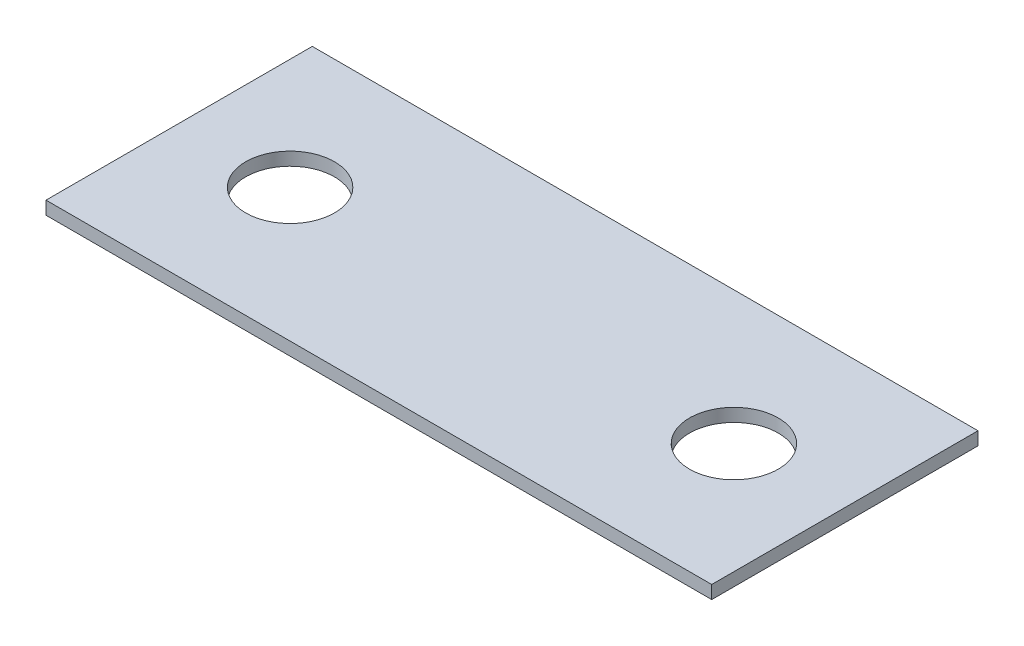
from build123d import *

# Parameters (mm, degrees)
SKETCH1_W           = 47.625
SKETCH1_H           = 19.05
BOSS_EXTRUDE1_DEPTH = 0.9375
CUT_EXTRUDE1_REACH  = 2.938
SKETCH2_R           = 3.175


with BuildPart() as part:
    # Sketch1 → Boss-Extrude1 (new body)
    with BuildSketch(Plane(origin=(0, 0, 0), x_dir=(1, 0, 0), z_dir=(0, 1, 0))):
        with Locations((23.8125, -9.525)):
            Rectangle(SKETCH1_W, SKETCH1_H)
    extrude(amount=BOSS_EXTRUDE1_DEPTH)

    # Sketch2 → Cut-Extrude1 (cut, up to next)
    with BuildSketch(Plane(origin=(0, 0.9375, 0), x_dir=(1, 0, 0), z_dir=(0, 1, 0)), mode=Mode.PRIVATE) as cut_extrude1_sk1:
        with Locations((7.9375, -9.525)):
            Circle(SKETCH2_R)
    cut_extrude1_tool1 = extrude(cut_extrude1_sk1.sketch, amount=-CUT_EXTRUDE1_REACH, mode=Mode.PRIVATE) & part.part
    add(cut_extrude1_tool1.solids().sort_by_distance((7.9375, 0.9375, 9.525))[0], mode=Mode.SUBTRACT)
    # Sketch2 → Cut-Extrude1 (cut, up to next)
    with BuildSketch(Plane(origin=(0, 0.9375, 0), x_dir=(1, 0, 0), z_dir=(0, 1, 0)), mode=Mode.PRIVATE) as cut_extrude1_sk2:
        with Locations((39.6875, -9.525)):
            Circle(SKETCH2_R)
    cut_extrude1_tool2 = extrude(cut_extrude1_sk2.sketch, amount=-CUT_EXTRUDE1_REACH, mode=Mode.PRIVATE) & part.part
    add(cut_extrude1_tool2.solids().sort_by_distance((39.6875, 0.9375, 9.525))[0], mode=Mode.SUBTRACT)


solid = part.part
